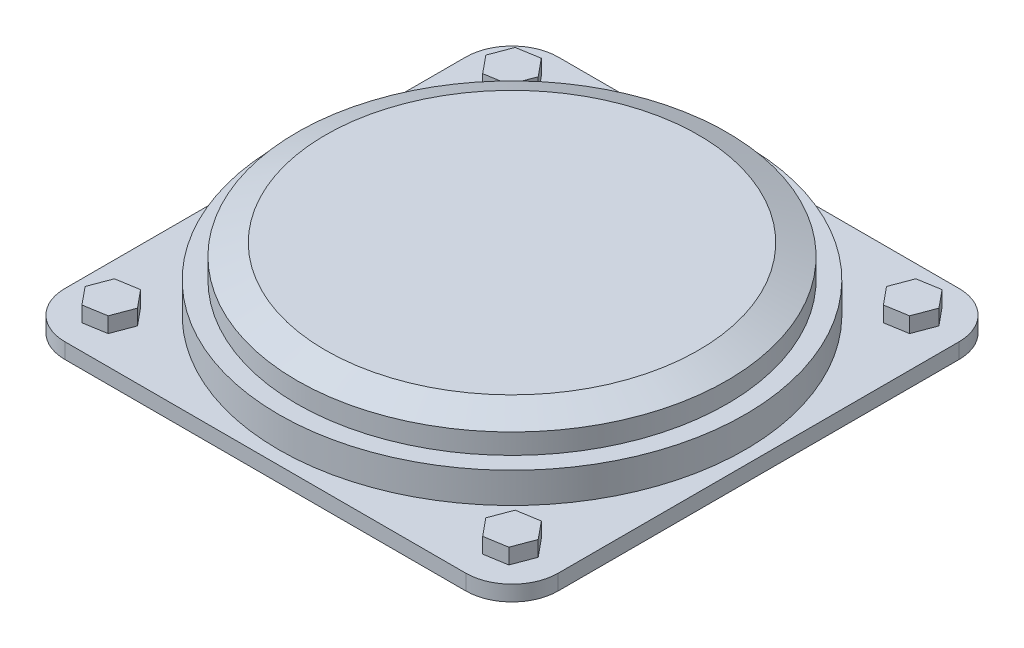
from build123d import *

# Parameters (mm, degrees)
SKETCH3_W             = 640
SKETCH3_H             = 640
BOSS_EXTRUDE1_DEPTH   = 20
FILLET1_R             = 60
BOSS_EXTRUDE2_DEPTH   = 20
BOSS_EXTRUDE2_2_DEPTH = 20
BOSS_EXTRUDE2_3_DEPTH = 20
BOSS_EXTRUDE2_4_DEPTH = 20


with BuildPart() as part:
    # Sketch2 → Revolve1 (revolve)
    with BuildSketch(Plane.XY):
        Polygon((-302.648705723, 206.85825101), (-302.648705723, 246.458690992), (-279.029523186, 246.458690992), (-279.029523186, 272.758953847), (-241.999065544, 288.320794667), (0, 288.320794667), (0, 206.85825101), align=None)
    revolve(axis=Axis((0, 288.320794667, 0), (0, -1, 0)))

    # Sketch3 → Boss-Extrude1 (add)
    with BuildSketch(Plane.XZ.offset(-206.85825101)):
        Rectangle(SKETCH3_W, SKETCH3_H)
    extrude(amount=BOSS_EXTRUDE1_DEPTH)

    # Fillet1
    fillet1_edges = [part.edges().sort_by_distance(p)[0] for p in [
        (-320, 196.85825101, 320),
        (-320, 196.85825101, -320),
        (320, 196.85825101, -320),
        (320, 196.85825101, 320),
    ]]
    fillet(fillet1_edges, radius=FILLET1_R)


with BuildPart() as body_2:
    # Sketch4 → Boss-Extrude2 (new body)
    with BuildSketch(Plane(origin=(0, 206.85825101, 0), x_dir=(1, 0, 0), z_dir=(0, 1, 0))):
        Polygon((278.768084989, -282.831023015), (289.15628842, -255.161873127), (270.388203431, -232.330850112), (241.231915011, -237.168976985), (230.84371158, -264.838126873), (249.611796569, -287.669149888), align=None)
    extrude(amount=BOSS_EXTRUDE2_DEPTH)


with BuildPart() as body_3:
    # Sketch4 → Boss-Extrude2 2 (new body)
    with BuildSketch(Plane(origin=(0, 206.85825101, 0), x_dir=(1, 0, 0), z_dir=(0, 1, 0))):
        Polygon((-241.231915011, -282.831023015), (-230.84371158, -255.161873127), (-249.611796569, -232.330850112), (-278.768084989, -237.168976985), (-289.15628842, -264.838126873), (-270.388203431, -287.669149888), align=None)
    extrude(amount=BOSS_EXTRUDE2_2_DEPTH)


with BuildPart() as body_4:
    # Sketch4 → Boss-Extrude2 3 (new body)
    with BuildSketch(Plane(origin=(0, 206.85825101, 0), x_dir=(1, 0, 0), z_dir=(0, 1, 0))):
        Polygon((230.84371158, 255.161873127), (249.611796569, 232.330850112), (278.768084989, 237.168976985), (289.15628842, 264.838126873), (270.388203431, 287.669149888), (241.231915011, 282.831023015), align=None)
    extrude(amount=BOSS_EXTRUDE2_3_DEPTH)


with BuildPart() as body_5:
    # Sketch4 → Boss-Extrude2 4 (new body)
    with BuildSketch(Plane(origin=(0, 206.85825101, 0), x_dir=(1, 0, 0), z_dir=(0, 1, 0))):
        Polygon((-289.15628842, 255.161873127), (-270.388203431, 232.330850112), (-241.231915011, 237.168976985), (-230.84371158, 264.838126873), (-249.611796569, 287.669149888), (-278.768084989, 282.831023015), align=None)
    extrude(amount=BOSS_EXTRUDE2_4_DEPTH)


solid = Compound([part.part, body_2.part, body_3.part, body_4.part, body_5.part])
